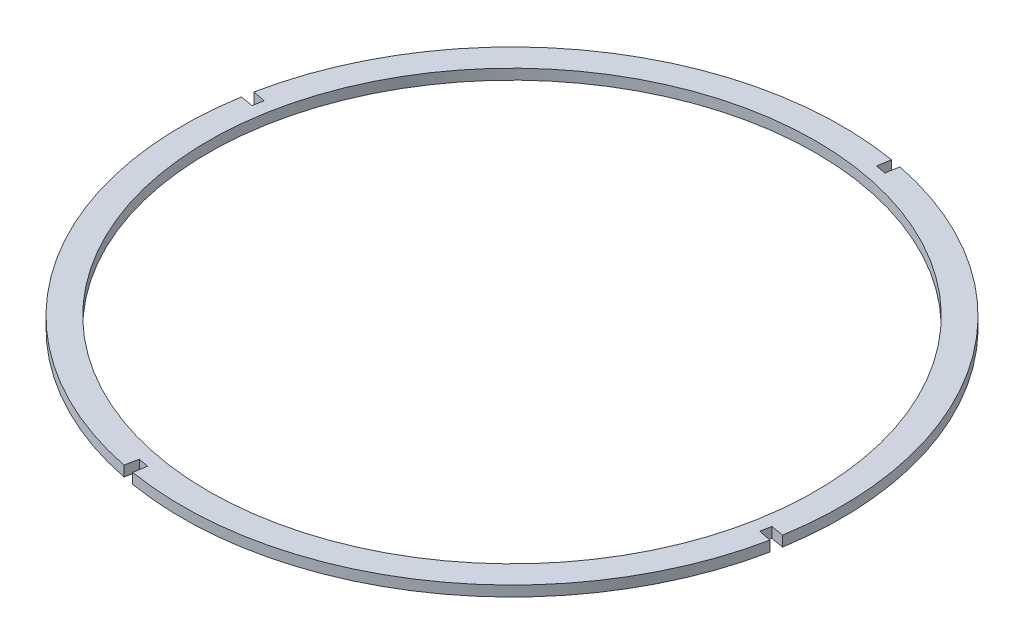
from build123d import *

# Parameters (mm, degrees)
SKETCH_1_R      = 467.03
EXTRUDE_4_DEPTH = 16


with BuildPart() as part:
    # Эскиз1 → Бобышка-Вытянуть4 (new body)
    with BuildSketch(Plane(origin=(0, 0, 0), x_dir=(1, 0, 0), z_dir=(0, 1, 0))):
        with BuildLine():
            Line((-322.977946121, 653.434451156), (-307.243442539, 650.531797712))
            Line((-307.243442539, 650.531797712), (-303.626576078, 670.137857951))
            ThreePointArc((-303.626576078, 670.137857951), (14.058646997, 460.70267508), (96.59440154, 89.25302034))
            Line((96.59440154, 89.25302034), (76.934130677, 92.54696455))
            Line((76.934130677, 92.54696455), (74.031477232, 76.812460968))
            Line((74.031477232, 76.812460968), (93.572957548, 72.874585153))
            ThreePointArc((93.572957548, 72.874585153), (-115.811795624, -244.499377508), (-486.958240872, -327.073727137))
            Line((-486.958240872, -327.073727137), (-483.676045344, -307.413856175))
            Line((-483.676045344, -307.413856175), (-499.411387282, -304.515750914))
            Line((-499.411387282, -304.515750914), (-503.338418417, -324.061751005))
            ThreePointArc((-503.338418417, -324.061751005), (-820.999697593, -114.619186519), (-903.525703591, 256.816318569))
            Line((-903.525703591, 256.816318569), (-883.865432727, 253.522374358))
            Line((-883.865432727, 253.522374358), (-880.962779283, 269.256877941))
            Line((-880.962779283, 269.256877941), (-900.568839522, 272.873744402))
            ThreePointArc((-900.568839522, 272.873744402), (-691.133656651, 590.558967477), (-319.684001911, 673.09472202))
            Line((-319.684001911, 673.09472202), (-322.977946121, 653.434451156))
        make_face()
        with Locations((-403.465651025, 173.034669454)):
            Circle(SKETCH_1_R, mode=Mode.SUBTRACT)
    extrude(amount=EXTRUDE_4_DEPTH)


solid = part.part
